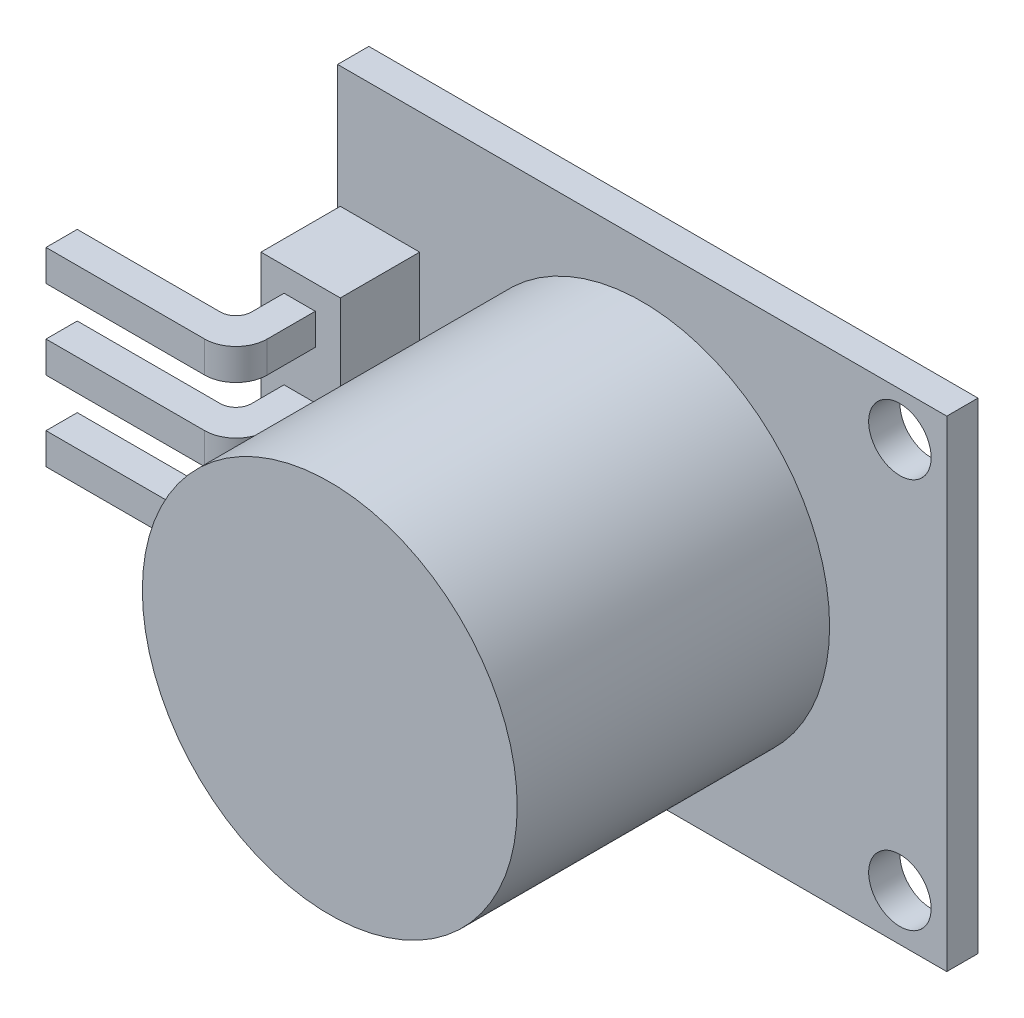
from build123d import *

# Parameters (mm, degrees)
CROQUIS1_W              = 19.5
CROQUIS1_H              = 15.4
CROQUIS1_R              = 1
SALIENTE_EXTRUIR1_DEPTH = 1
CROQUIS2_R              = 6
SALIENTE_EXTRUIR2_DEPTH = 10
CROQUIS3_W              = 2.54
CROQUIS3_H              = 7.62
SALIENTE_EXTRUIR3_DEPTH = 2.54
CROQUIS4_W              = 1
CROQUIS4_H              = 1
SALIENTE_EXTRUIR4_DEPTH = 2.54
CROQUIS6_W              = 1
CROQUIS6_H              = 1
SALIENTE_EXTRUIR5_DEPTH = 5.08
REDONDEO2_R             = 1
REDONDEO3_R             = 1
REDONDEO4_R             = 1
REDONDEO5_R             = 0.5
REDONDEO6_R             = 0.5
REDONDEO7_R             = 0.5


with BuildPart() as part:
    # Croquis1 → Saliente-Extruir1 (new body)
    with BuildSketch(Plane.XY):
        with Locations((-9.362960818, 4.807039504)):
            Rectangle(CROQUIS1_W, CROQUIS1_H)
        with Locations((-1.112960818, -1.392960496)):
            Circle(CROQUIS1_R, mode=Mode.SUBTRACT)
        with Locations((-1.112960818, 11.107039504)):
            Circle(CROQUIS1_R, mode=Mode.SUBTRACT)
    extrude(amount=SALIENTE_EXTRUIR1_DEPTH)

    # Croquis2 → Saliente-Extruir2 (add)
    with BuildSketch(Plane.XY.offset(1)):
        with Locations((-9.362960818, 4.807039504)):
            Circle(CROQUIS2_R)
    extrude(amount=SALIENTE_EXTRUIR2_DEPTH)

    # Croquis3 → Saliente-Extruir3 (add)
    with BuildSketch(Plane.XY.offset(1)):
        with Locations((-17.75568674, 4.807039504)):
            Rectangle(CROQUIS3_W, CROQUIS3_H)
    extrude(amount=SALIENTE_EXTRUIR3_DEPTH)

    # Croquis4 → Saliente-Extruir4 (add)
    with BuildSketch(Plane.XY.offset(3.54)):
        with Locations((-17.786846734, 7.347039504)):
            Rectangle(CROQUIS4_W, CROQUIS4_H)
        with Locations((-17.786846734, 4.807039504)):
            Rectangle(CROQUIS4_W, CROQUIS4_H)
        with Locations((-17.786846734, 2.267039504)):
            Rectangle(CROQUIS4_W, CROQUIS4_H)
    extrude(amount=SALIENTE_EXTRUIR4_DEPTH)

    # Croquis6 → Saliente-Extruir5 (add)
    with BuildSketch(Plane.ZY.offset(18.286846734)):
        with Locations((5.58, 4.807039504)):
            Rectangle(CROQUIS6_W, CROQUIS6_H)
        with Locations((5.58, 2.267039504)):
            Rectangle(CROQUIS6_W, CROQUIS6_H)
        with Locations((5.58, 7.347039504)):
            Rectangle(CROQUIS6_W, CROQUIS6_H)
    extrude(amount=SALIENTE_EXTRUIR5_DEPTH)

    # Redondeo2
    redondeo2_edges = [part.edges().sort_by_distance(p)[0] for p in [
        (-17.286846734, 2.267039504, 6.08),
    ]]
    fillet(redondeo2_edges, radius=REDONDEO2_R)

    # Redondeo3
    redondeo3_edges = [part.edges().sort_by_distance(p)[0] for p in [
        (-17.286846734, 4.807039504, 6.08),
    ]]
    fillet(redondeo3_edges, radius=REDONDEO3_R)

    # Redondeo4
    redondeo4_edges = [part.edges().sort_by_distance(p)[0] for p in [
        (-17.286846734, 7.347039504, 6.08),
    ]]
    fillet(redondeo4_edges, radius=REDONDEO4_R)

    # Redondeo5
    redondeo5_edges = [part.edges().sort_by_distance(p)[0] for p in [
        (-18.286846734, 2.267039504, 5.08),
    ]]
    fillet(redondeo5_edges, radius=REDONDEO5_R)

    # Redondeo6
    redondeo6_edges = [part.edges().sort_by_distance(p)[0] for p in [
        (-18.286846734, 4.807039504, 5.08),
    ]]
    fillet(redondeo6_edges, radius=REDONDEO6_R)

    # Redondeo7
    redondeo7_edges = [part.edges().sort_by_distance(p)[0] for p in [
        (-18.286846734, 7.347039504, 5.08),
    ]]
    fillet(redondeo7_edges, radius=REDONDEO7_R)


solid = part.part
